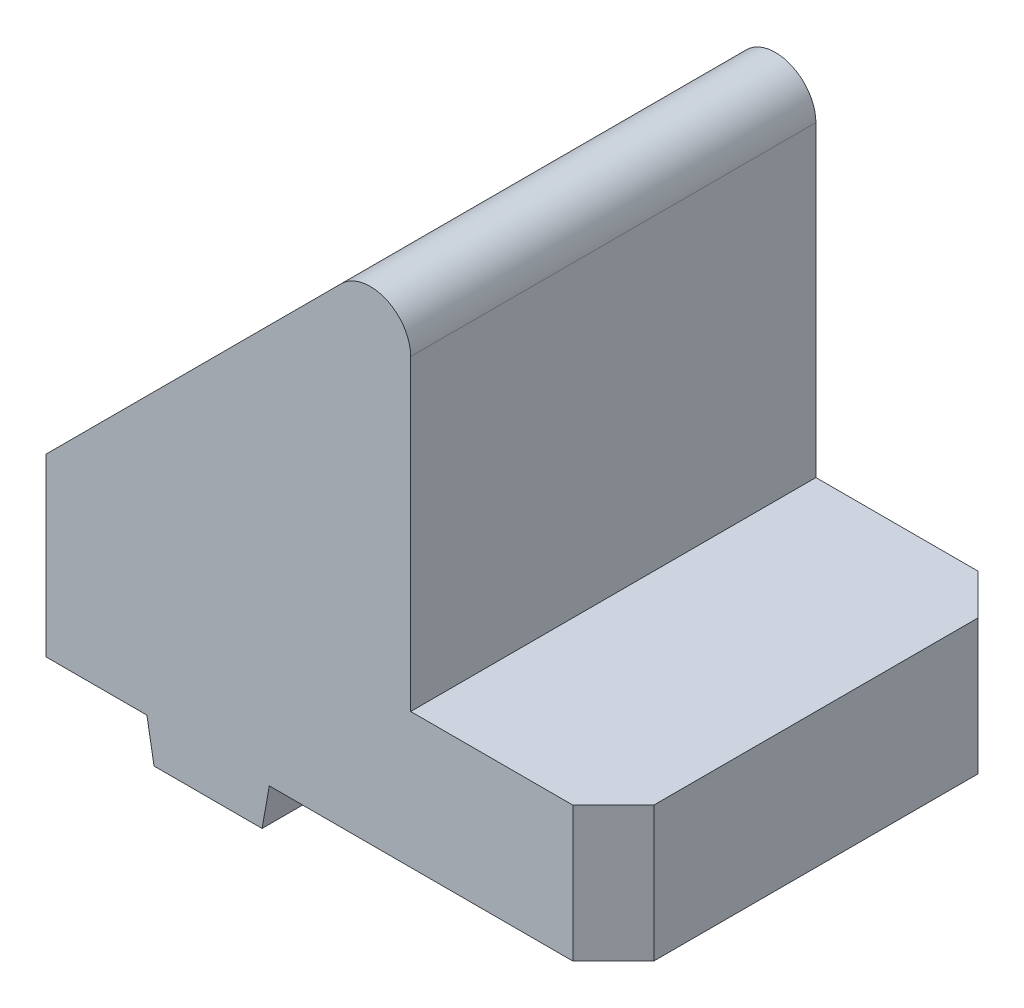
from build123d import *

# Parameters (mm, degrees)
SALIENTE_EXTRUIR1_DEPTH = 15
CHAFL_N1_SIZE           = 3
CORTAR_EXTRUIR1_START   = -10
CROQUIS3_W              = 16
CROQUIS3_H              = 16
CORTAR_EXTRUIR1_DEPTH   = 31
CHAFL_N2_SIZE           = 3
CROQUIS4_R              = 3.2
CORTAR_EXTRUIR2_DEPTH   = 14
REDONDEO1_R             = 3


with BuildPart() as part:
    # Croquis1 → Saliente-Extruir1 (new body, symmetric)
    with BuildSketch(Plane.XY):
        Polygon((-30, 0), (-30, 10), (0, 40), (0, 10), (15, 10), (15, 0), (0, 0), (-10.471019058, 0), (-11, -3), (-19, -3), (-19.528980942, 0), align=None)
    extrude(amount=SALIENTE_EXTRUIR1_DEPTH, both=True)

    # Chaflán1
    chafl_n1_edges = [part.edges().sort_by_distance(p)[0] for p in [
        (-30, 5, -15),
        (15, 5, 15),
        (15, 5, -15),
        (-30, 5, 15),
    ]]
    chamfer(chafl_n1_edges, length=CHAFL_N1_SIZE)

    # Croquis3 → Cortar-Extruir1 (cut, through all)
    with BuildSketch(Plane.XZ.offset(CORTAR_EXTRUIR1_START)):
        with Locations((-15, 0)):
            Rectangle(CROQUIS3_W, CROQUIS3_H)
    extrude(amount=-CORTAR_EXTRUIR1_DEPTH, mode=Mode.SUBTRACT)

    # Chaflán2
    chafl_n2_edges = [part.edges().sort_by_distance(p)[0] for p in [
        (-23, 13.5, -8),
        (-23, 13.5, 8),
        (-7, 21.5, 8),
        (-7, 21.5, -8),
    ]]
    chamfer(chafl_n2_edges, length=CHAFL_N2_SIZE)

    # Croquis4 → Cortar-Extruir2 (cut, through all)
    with BuildSketch(Plane(origin=(0, 10, 0), x_dir=(1, 0, 0), z_dir=(0, 1, 0))):
        with Locations((-15, 0)):
            Circle(CROQUIS4_R)
    extrude(amount=-CORTAR_EXTRUIR2_DEPTH, mode=Mode.SUBTRACT)

    # Redondeo1
    redondeo1_edges = [part.edges().sort_by_distance(p)[0] for p in [
        (0, 40, 0),
    ]]
    fillet(redondeo1_edges, radius=REDONDEO1_R)


solid = part.part
